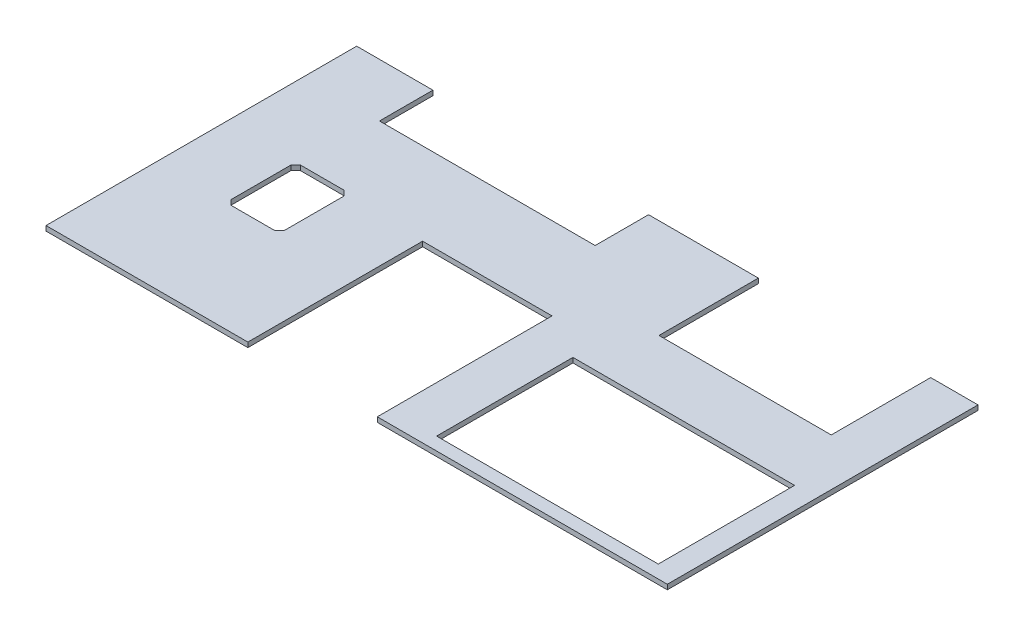
from build123d import *

# Parameters (mm, degrees)
SKETCH1_W           = 2438.4
SKETCH1_H           = 1219.2
BOSS_EXTRUDE1_DEPTH = 19.05
SKETCH2_W           = 869.95
SKETCH2_H           = 534.9875
CUT_EXTRUDE1_DEPTH  = 20.05
SKETCH3_W           = 508
SKETCH3_H           = 685.8
CUT_EXTRUDE2_DEPTH  = 20.05
SKETCH4_W           = 676.20134
SKETCH4_H           = 863.85146
CUT_EXTRUDE3_DEPTH  = 20.05
SKETCH5_W           = 846.4296
SKETCH5_H           = 206.375
CUT_EXTRUDE4_DEPTH  = 20.05
CUT_EXTRUDE6_DEPTH  = 20.05
CUT_EXTRUDE7_DEPTH  = 846.4296


with BuildPart() as part:
    # Sketch1 → Boss-Extrude1 (new body)
    with BuildSketch(Plane(origin=(0, 0, 0), x_dir=(1, 0, 0), z_dir=(0, 1, 0))):
        with Locations((1219.2, 609.6)):
            Rectangle(SKETCH1_W, SKETCH1_H)
    extrude(amount=-BOSS_EXTRUDE1_DEPTH)

    # Sketch2 → Cut-Extrude1 (cut, through all)
    with BuildSketch(Plane(origin=(0, 0, 0), x_dir=(1, 0, 0), z_dir=(0, 1, 0))):
        with Locations((1917.065, 318.29375)):
            Rectangle(SKETCH2_W, SKETCH2_H)
    extrude(amount=-CUT_EXTRUDE1_DEPTH, mode=Mode.SUBTRACT)

    # Sketch3 → Cut-Extrude2 (cut, through all)
    with BuildSketch(Plane(origin=(0, 0, 0), x_dir=(1, 0, 0), z_dir=(0, 1, 0))):
        with Locations((1046.1625, 342.9)):
            Rectangle(SKETCH3_W, SKETCH3_H)
    extrude(amount=-CUT_EXTRUDE2_DEPTH, mode=Mode.SUBTRACT)

    # Sketch4 → Cut-Extrude3 (cut, through all)
    with BuildSketch(Plane(origin=(0, 0, 0), x_dir=(1, 0, 0), z_dir=(0, 1, 0))):
        with Locations((1914.52627, 1260.98427)):
            Rectangle(SKETCH4_W, SKETCH4_H)
    extrude(amount=-CUT_EXTRUDE3_DEPTH, mode=Mode.SUBTRACT)

    # Sketch5 → Cut-Extrude4 (cut, through all)
    with BuildSketch(Plane(origin=(0, 0, 0), x_dir=(1, 0, 0), z_dir=(0, 1, 0))):
        with Locations((722.3252, 1116.0125)):
            Rectangle(SKETCH5_W, SKETCH5_H)
    extrude(amount=-CUT_EXTRUDE4_DEPTH, mode=Mode.SUBTRACT)

    # Sketch8 → Cut-Extrude6 (cut, through all)
    with BuildSketch(Plane(origin=(0, 0, 0), x_dir=(1, 0, 0), z_dir=(0, 1, 0))):
        Polygon((294.0685, 704.85), (275.0185, 685.8), (275.0185, 450.85), (294.0685, 431.8), (465.5185, 431.8), (484.5685, 450.85), (484.5685, 685.8), (465.5185, 704.85), align=None)
    extrude(amount=-CUT_EXTRUDE6_DEPTH, mode=Mode.SUBTRACT)

    # Sketch9 → Cut-Extrude7 (cut)
    with BuildSketch(Plane.ZY.offset(-299.1104)):
        with BuildLine():
            Line((-1009.601754844, 0), (-1219.2, 0))
            Line((-1219.2, 0), (-1219.2, -19.05))
            Line((-1219.2, -19.05), (-1005.293201675, -19.05))
            ThreePointArc((-1005.293201675, -19.05), (-1007.340207177, -9.500738417), (-1009.601754844, 0))
        make_face()
    extrude(amount=-CUT_EXTRUDE7_DEPTH, mode=Mode.SUBTRACT)


solid = part.part
